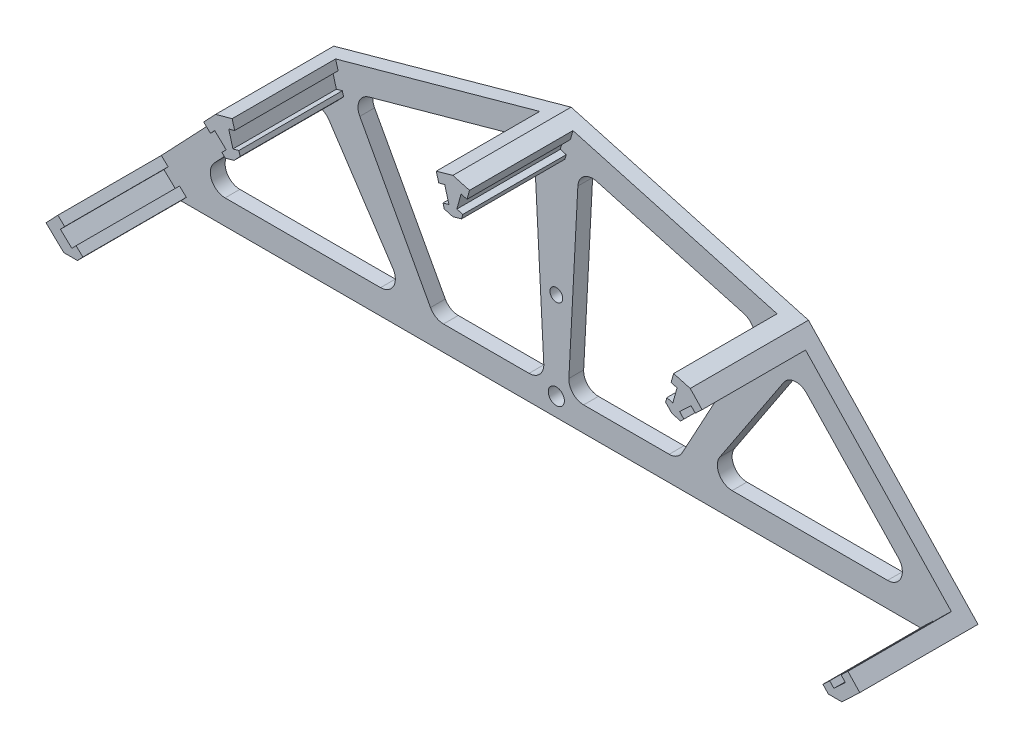
from build123d import *

# Parameters (mm, degrees)
BOSS_EXTRUDE1_DEPTH = 3
BOSS_EXTRUDE2_DEPTH = 21
SKETCH3_R           = 1.642484664
SKETCH3_R_2         = 1.292978033
CUT_EXTRUDE1_DEPTH  = 98.218880344


with BuildPart() as part:
    # Sketch1 → Boss-Extrude1 (new body)
    with BuildSketch(Plane.XY):
        Polygon((-82.599251445, -2.855918156), (-78.97237959, -6.297691035), (78.97237959, -6.297691035), (82.599251445, -2.855918156), (48.18152266, 33.412800394), (0, 46.774719198), (-48.18152266, 33.412800394), align=None)
    extrude(amount=BOSS_EXTRUDE1_DEPTH)

    # Sketch2 → Boss-Extrude2 (add)
    with BuildSketch(Plane.XY.offset(3)):
        Polygon((-44.808816074, 34.34813471), (-48.18152266, 33.412800394), (-50.590763675, 30.873990096), (-49.21255237, 29.566116402), (-48.352109151, 30.472834366), (-46.030911164, 28.270099723), (-46.891354383, 27.36338176), (-46.192513036, 26.700206083), (-44.440185395, 27.186169547), (-43.188437129, 28.505236993), (-43.445900356, 29.433619399), (-44.650438423, 29.099571429), (-45.505601226, 32.183188879), (-44.30106316, 32.517236849), align=None)
        Polygon((0, 46.774719198), (-3.372706586, 45.839384882), (-2.864953672, 44.008487021), (-1.660415605, 44.342534991), (-0.805252802, 41.25891754), (-2.009790868, 40.92486957), (-1.752327641, 39.996487164), (0, 39.5105237), (1.752327641, 39.996487164), (2.009790868, 40.92486957), (0.805252802, 41.25891754), (1.660415605, 44.342534991), (2.864953672, 44.008487021), (3.372706586, 45.839384882), align=None)
        Polygon((-78.811799125, -1.624981552), (-80.19001043, -0.317107858), (-82.599251445, -2.855918156), (-78.97237959, -6.297691035), (-76.215182645, -6.297691035), (-75.112389833, -5.135589888), (-76.490601138, -3.827716194), (-77.351044358, -4.734434158), (-79.672242345, -2.531699516), align=None)
        Polygon((48.18152266, 33.412800394), (44.808816074, 34.34813471), (44.30106316, 32.517236849), (45.505601226, 32.183188879), (44.650438423, 29.099571429), (43.445900356, 29.433619399), (43.188437129, 28.505236993), (44.440185395, 27.186169547), (46.192513036, 26.700206083), (46.891354383, 27.36338176), (46.030911164, 28.270099723), (48.352109151, 30.472834366), (49.21255237, 29.566116402), (50.590763675, 30.873990096), align=None)
        Polygon((75.112389833, -5.135589888), (76.215182645, -6.297691035), (78.97237959, -6.297691035), (82.599251445, -2.855918156), (80.19001043, -0.317107858), (78.811799125, -1.624981552), (79.672242345, -2.531699516), (77.351044358, -4.734434158), (76.490601138, -3.827716194), align=None)
    extrude(amount=BOSS_EXTRUDE2_DEPTH)

    # Sketch3 → Cut-Extrude1 (cut, through all)
    with BuildSketch(Plane.XY.offset(3)):
        with Locations((0, -2.554468846)):
            Circle(SKETCH3_R)
        with Locations((0, 15.270369354)):
            Circle(SKETCH3_R_2)
        with BuildLine():
            Line((-69.420990751, 3.767372692), (-50.828151114, 23.360137575))
            ThreePointArc((-50.828151114, 23.360137575), (-48.390560772, 24.283657942), (-46.150370534, 22.950884804))
            Line((-46.150370534, 22.950884804), (-33.182202355, 3.358119921))
            ThreePointArc((-33.182202355, 3.358119921), (-33.041187606, 0.282349963), (-35.683859821, -1.297691035))
            Line((-35.683859821, -1.297691035), (-67.244867638, -1.297691035))
            ThreePointArc((-67.244867638, -1.297691035), (-70.001241269, 0.518077396), (-69.420990751, 3.767372692))
        make_face()
        with BuildLine():
            Line((-25.543650537, 0.270832684), (-39.897767636, 26.707827652))
            ThreePointArc((-39.897767636, 26.707827652), (-40.022830858, 29.311497318), (-38.063031426, 31.030195292))
            Line((-38.063031426, 31.030195292), (-8.166425929, 39.321257781))
            ThreePointArc((-8.166425929, 39.321257781), (-5.611961803, 38.865088367), (-4.368822196, 36.58737429))
            Line((-4.368822196, 36.58737429), (-2.548801826, 1.859316834))
            ThreePointArc((-2.548801826, 1.859316834), (-3.368567317, -0.362754762), (-5.54469043, -1.297691035))
            Line((-5.54469043, -1.297691035), (-22.907199199, -1.297691035))
            ThreePointArc((-22.907199199, -1.297691035), (-24.441078457, -0.875910269), (-25.543650537, 0.270832684))
        make_face()
        with BuildLine():
            Line((5.54469043, -1.297691035), (22.907199199, -1.297691035))
            ThreePointArc((22.907199199, -1.297691035), (24.441078457, -0.875910269), (25.543650537, 0.270832684))
            Line((25.543650537, 0.270832684), (39.897767636, 26.707827652))
            ThreePointArc((39.897767636, 26.707827652), (40.022830858, 29.311497318), (38.063031426, 31.030195292))
            Line((38.063031426, 31.030195292), (8.166425929, 39.321257781))
            ThreePointArc((8.166425929, 39.321257781), (5.611961803, 38.865088367), (4.368822196, 36.58737429))
            Line((4.368822196, 36.58737429), (2.548801826, 1.859316834))
            ThreePointArc((2.548801826, 1.859316834), (3.368567317, -0.362754762), (5.54469043, -1.297691035))
        make_face()
        with BuildLine():
            Line((35.683859821, -1.297691035), (67.244867638, -1.297691035))
            ThreePointArc((67.244867638, -1.297691035), (70.001241269, 0.518077396), (69.420990751, 3.767372692))
            Line((69.420990751, 3.767372692), (50.828151114, 23.360137575))
            ThreePointArc((50.828151114, 23.360137575), (48.390560772, 24.283657942), (46.150370534, 22.950884804))
            Line((46.150370534, 22.950884804), (33.182202355, 3.358119921))
            ThreePointArc((33.182202355, 3.358119921), (33.041187606, 0.282349963), (35.683859821, -1.297691035))
        make_face()
    extrude(amount=-CUT_EXTRUDE1_DEPTH, mode=Mode.SUBTRACT)


solid = part.part
